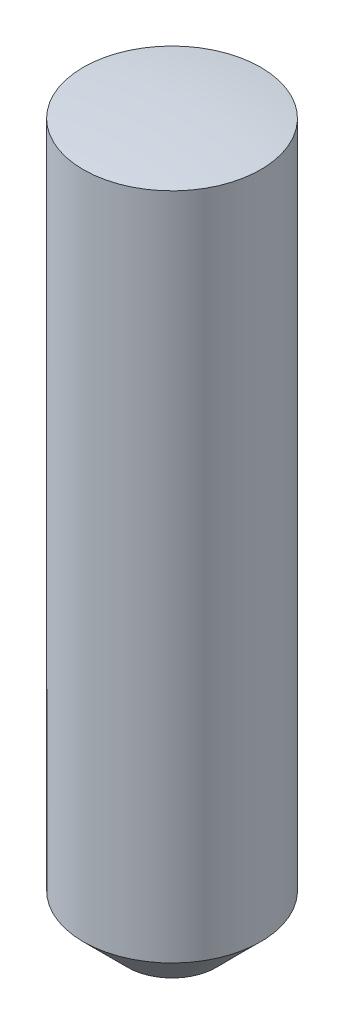
from build123d import *

# Parameters (mm, degrees)
SKETCH1_R                 = 1
BOSS_EXTRUDE_8_10MM_DEPTH = 8.1
F_0_5_X_45_DEG_SIZE       = 0.5


with BuildPart() as part:
    # Sketch1 → Boss-Extrude 8.10mm (new body)
    with BuildSketch(Plane(origin=(0, 0, 0), x_dir=(1, 0, 0), z_dir=(0, 1, 0))):
        Circle(SKETCH1_R)
    extrude(amount=-BOSS_EXTRUDE_8_10MM_DEPTH)

    # 0.5 x 45 deg
    f_0_5_x_45_deg_edges = [part.edges().sort_by_distance(p)[0] for p in [
        (-1, -8.1, 0),
    ]]
    chamfer(f_0_5_x_45_deg_edges, length=F_0_5_X_45_DEG_SIZE)

    # Sketch2 → SR8 (revolve, cut)
    with BuildSketch(Plane.XY):
        with BuildLine():
            Line((0, 2), (-2, 2))
            Line((-2, 2), (-2, -0.254033308))
            ThreePointArc((-2, -0.254033308), (-1.00803434, -0.06376243), (0, 0))
            Line((0, 0), (0, 2))
        make_face()
    revolve(axis=Axis((0, 0, 0), (0, 1, 0)), mode=Mode.SUBTRACT)


solid = part.part
